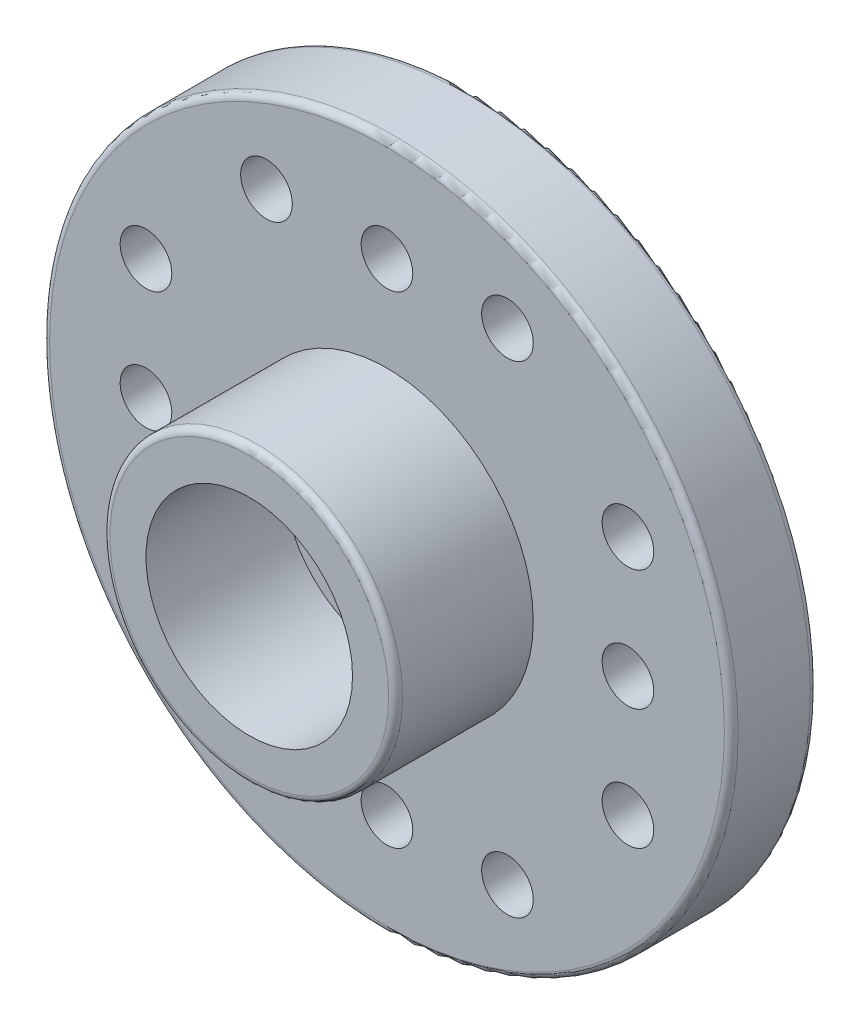
from build123d import *

# Parameters (mm, degrees)
SKETCH1_R           = 10
SKETCH1_R_2         = 0.75
SKETCH1_R_3         = 1.5
BOSS_EXTRUDE1_DEPTH = 2.5
SKETCH5_R           = 4.25
SKETCH5_R_2         = 3
BOSS_EXTRUDE2_DEPTH = 4
SKETCH6_R           = 4.5
CUT_EXTRUDE1_DEPTH  = 0.8
SKETCH7_R           = 3.7
SKETCH7_R_2         = 3.5
BOSS_EXTRUDE3_DEPTH = 0.8
FILLET1_R           = 0.2


with BuildPart() as part:
    # Sketch1 → Boss-Extrude1 (new body)
    with BuildSketch(Plane.XY):
        Circle(SKETCH1_R)
        with Locations((-7, 0)):
            Circle(SKETCH1_R_2, mode=Mode.SUBTRACT)
        with Locations((3.5, 7)):
            Circle(SKETCH1_R_2, mode=Mode.SUBTRACT)
        with Locations((0, 7)):
            Circle(SKETCH1_R_2, mode=Mode.SUBTRACT)
        with Locations((-3.5, 7)):
            Circle(SKETCH1_R_2, mode=Mode.SUBTRACT)
        with Locations((7, -3.5)):
            Circle(SKETCH1_R_2, mode=Mode.SUBTRACT)
        with Locations((7, 0)):
            Circle(SKETCH1_R_2, mode=Mode.SUBTRACT)
        with Locations((7, 3.5)):
            Circle(SKETCH1_R_2, mode=Mode.SUBTRACT)
        with Locations((-3.5, -7)):
            Circle(SKETCH1_R_2, mode=Mode.SUBTRACT)
        with Locations((0, -7)):
            Circle(SKETCH1_R_2, mode=Mode.SUBTRACT)
        with Locations((3.5, -7)):
            Circle(SKETCH1_R_2, mode=Mode.SUBTRACT)
        with Locations((-7, -3.5)):
            Circle(SKETCH1_R_2, mode=Mode.SUBTRACT)
        with Locations((-7, 3.5)):
            Circle(SKETCH1_R_2, mode=Mode.SUBTRACT)
        Circle(SKETCH1_R_3, mode=Mode.SUBTRACT)
    extrude(amount=BOSS_EXTRUDE1_DEPTH)

    # Sketch5 → Boss-Extrude2 (add)
    with BuildSketch(Plane.XY.offset(2.5)):
        Circle(SKETCH5_R)
        Circle(SKETCH5_R_2, mode=Mode.SUBTRACT)
    extrude(amount=BOSS_EXTRUDE2_DEPTH)

    # Sketch6 → Cut-Extrude1 (cut)
    with BuildSketch(Plane(origin=(0, 0, 0), x_dir=(-1, 0, 0), z_dir=(0, 0, -1))):
        Circle(SKETCH6_R)
    extrude(amount=-CUT_EXTRUDE1_DEPTH, mode=Mode.SUBTRACT)

    # Sketch7 → Boss-Extrude3 (add)
    with BuildSketch(Plane(origin=(0, 0, 0.8), x_dir=(-1, 0, 0), z_dir=(0, 0, -1))):
        with Locations((0.162730827, 0)):
            Circle(SKETCH7_R)
        with Locations((0.162730827, 0)):
            Circle(SKETCH7_R_2, mode=Mode.SUBTRACT)
    extrude(amount=BOSS_EXTRUDE3_DEPTH)

    # Fillet1
    fillet1_edges = [part.edges().sort_by_distance(p)[0] for p in [
        (-10, 0, 0),
        (-10, 0, 2.5),
        (-4.25, 0, 6.5),
        (4.5, 0, 0),
    ]]
    fillet(fillet1_edges, radius=FILLET1_R)


solid = part.part
